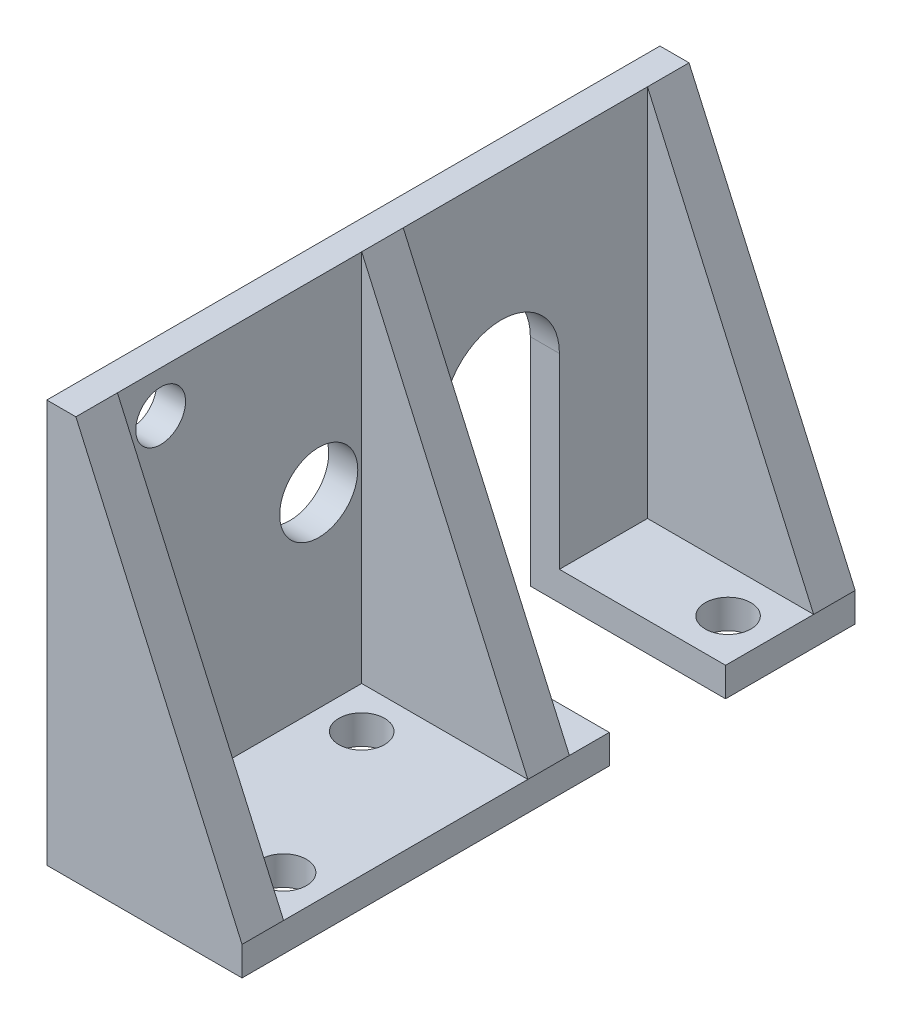
from build123d import *

# Parameters (mm, degrees)
SKETCH1_W                   = 36.9
SKETCH1_H                   = 22.5
BASEPLATE_DEPTH             = 1.75
SKETCH2_W                   = 11.75
SKETCH2_H                   = 36.9
BOSS_EXTRUDE2_DEPTH         = 1.75
SUPPORT1_REACH              = 46.788
SKETCH3_WALL_W              = 116.197196834
SKETCH3_WALL_H              = 2.5
SUPPORT3_REACH              = 33.38
SKETCH4_WALL_W              = 89.382482298
SKETCH4_WALL_H              = 2.5
SKETCH5_R                   = 1.5
MOTOR_MOUNTINGHOLES_DEPTH   = 45.360568076
SHAFTSLOT_DEPTH             = 45.787526165
SKETCH8_R                   = 1.375
CHASSIS_MOUNTINGHOLES_DEPTH = 45.787526165
SKETCH9_R                   = 2.35
INDENTHOLE_DEPTH            = 10


with BuildPart() as part:
    # Sketch1 → basePlate (new body)
    with BuildSketch(Plane(origin=(0, 0, 0), x_dir=(0, 0, -1), z_dir=(1, 0, 0))):
        with Locations((18.45, 11.25)):
            Rectangle(SKETCH1_W, SKETCH1_H)
    extrude(amount=BASEPLATE_DEPTH)

    # Sketch2 → Boss-Extrude2 (add)
    with BuildSketch(Plane.XZ):
        with Locations((5.875, -18.45)):
            Rectangle(SKETCH2_W, SKETCH2_H)
    extrude(amount=BOSS_EXTRUDE2_DEPTH)

    # Sketch3 wall → support1 (add, up to next)
    with BuildSketch(Plane(origin=(6.75, 11.25, 0), x_dir=(0.406138466053, -0.91381154862, 0), z_dir=(0.91381154862, 0.406138466053, 0)), mode=Mode.PRIVATE) as support1_sk1:
        with Locations((0, 1.25)):
            Rectangle(SKETCH3_WALL_W, SKETCH3_WALL_H)
    support1_tool1 = extrude(support1_sk1.sketch, amount=-SUPPORT1_REACH, mode=Mode.PRIVATE) - part.part
    support1 = support1_tool1.solids().sort_by_distance((6.75, 11.25, 0))[0]
    add(support1)

    # support2: support1 across plane
    add(support1.mirror(Plane.XY.offset(-18.45)))

    # Sketch4 wall → support3 (add, up to next)
    with BuildSketch(Plane(origin=(6.75, 11.25, -18.45), x_dir=(0.406138466053, -0.91381154862, 0), z_dir=(0.91381154862, 0.406138466053, 0)), mode=Mode.PRIVATE) as support3_sk1:
        Rectangle(SKETCH4_WALL_W, SKETCH4_WALL_H)
    support3_tool1 = extrude(support3_sk1.sketch, amount=-SUPPORT3_REACH, mode=Mode.PRIVATE) - part.part
    add(support3_tool1.solids().sort_by_distance((6.75, 11.25, -18.45))[0])

    # Sketch5 → motor_mountingHoles (cut, through all)
    with BuildSketch(Plane(origin=(1.75, 0, 0), x_dir=(0, 0, -1), z_dir=(1, 0, 0))):
        with Locations((5.1, 2.5)):
            Circle(SKETCH5_R)
        with Locations((5.1, 20)):
            Circle(SKETCH5_R)
    extrude(amount=-MOTOR_MOUNTINGHOLES_DEPTH, mode=Mode.SUBTRACT)

    # Sketch7 → shaftSlot (cut, through all)
    with BuildSketch(Plane(origin=(11.75, 0, 0), x_dir=(0, 0, -1), z_dir=(1, 0, 0))):
        with BuildLine():
            Line((22.1, -1.75), (22.1, 11.25))
            ThreePointArc((22.1, 11.25), (25.6, 14.75), (29.1, 11.25))
            Line((29.1, 11.25), (29.1, -1.75))
            Line((29.1, -1.75), (22.1, -1.75))
        make_face()
    extrude(amount=-SHAFTSLOT_DEPTH, mode=Mode.SUBTRACT)

    # Sketch8 → chassis_mountingHoles (cut, through all)
    with BuildSketch(Plane(origin=(0, 0, 0), x_dir=(1, 0, 0), z_dir=(0, 1, 0))):
        with Locations(Location((9.25, 5, 0), (0, 0, 270))):
            Circle(SKETCH8_R)
        with Locations(Location((4.25, 14.7, 0), (0, 0, 270))):
            Circle(SKETCH8_R)
        with Locations(Location((9.25, 31.75, 0), (0, 0, 270))):
            Circle(SKETCH8_R)
    extrude(amount=-CHASSIS_MOUNTINGHOLES_DEPTH, mode=Mode.SUBTRACT)

    # Sketch9 → indentHole (cut)
    with BuildSketch(Plane(origin=(1.75, 0, 0), x_dir=(0, 0, -1), z_dir=(1, 0, 0))):
        with Locations((14.615, 11.25)):
            Circle(SKETCH9_R)
    extrude(amount=-INDENTHOLE_DEPTH, mode=Mode.SUBTRACT)


solid = part.part
